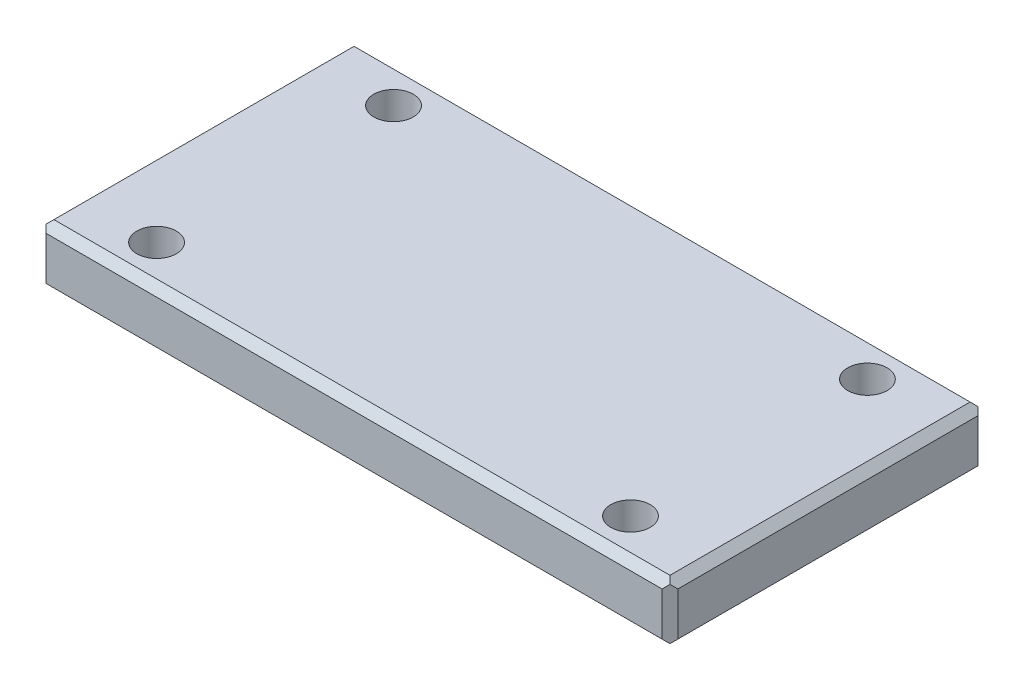
from build123d import *

# Parameters (mm, degrees)
SKETCH1_W           = 4
SKETCH1_H           = 2
SKETCH1_R           = 0.125
BOSS_EXTRUDE1_DEPTH = 0.1875
CHAMFER1_SIZE       = 0.05
CHAMFER2_SIZE       = 0.05


with BuildPart() as part:
    # Sketch1 → Boss-Extrude1 (new body, symmetric)
    with BuildSketch(Plane(origin=(0, 0, 0), x_dir=(1, 0, 0), z_dir=(0, 1, 0))):
        Rectangle(SKETCH1_W, SKETCH1_H)
        with Locations((-1.5, 0.75)):
            Circle(SKETCH1_R, mode=Mode.SUBTRACT)
        with Locations((1.5, 0.75)):
            Circle(SKETCH1_R, mode=Mode.SUBTRACT)
        with Locations((1.5, -0.75)):
            Circle(SKETCH1_R, mode=Mode.SUBTRACT)
        with Locations((-1.5, -0.75)):
            Circle(SKETCH1_R, mode=Mode.SUBTRACT)
    extrude(amount=BOSS_EXTRUDE1_DEPTH, both=True)

    # Chamfer1
    chamfer1_edges = [part.edges().sort_by_distance(p)[0] for p in [
        (2, 0.1875, 0),
        (0, 0.1875, -1),
        (-2, 0.1875, 0),
        (0, -0.1875, -1),
        (2, -0.1875, 0),
        (0, -0.1875, 1),
        (-2, -0.1875, 0),
        (0, 0.1875, 1),
    ]]
    chamfer(chamfer1_edges, length=CHAMFER1_SIZE)

    # Chamfer2
    chamfer2_edges = [part.edges().sort_by_distance(p)[0] for p in [
        (-2, 0, 1),
        (-2, 0, -1),
        (2, 0, 1),
        (2, 0, -1),
    ]]
    chamfer(chamfer2_edges, length=CHAMFER2_SIZE)


solid = part.part
